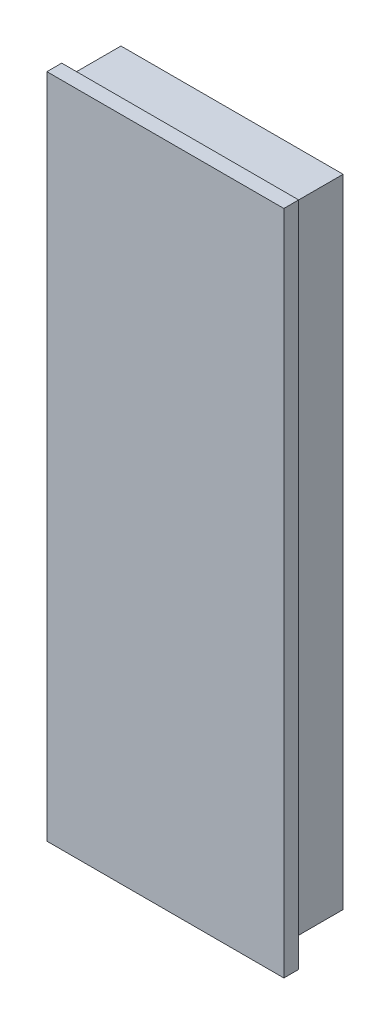
from build123d import *

# Parameters (mm, degrees)
SKETCH_1_W      = 15
SKETCH_1_H      = 43
EXTRUDE_1_DEPTH = 4
SKETCH_2_W      = 16
SKETCH_2_H      = 45
EXTRUDE_2_DEPTH = 1


with BuildPart() as part:
    # 草图1 → 凸台-拉伸1 (new body)
    with BuildSketch(Plane.XY):
        Rectangle(SKETCH_1_W, SKETCH_1_H)
    extrude(amount=EXTRUDE_1_DEPTH)

    # 草图2 → 凸台-拉伸2 (add)
    with BuildSketch(Plane.XY.offset(4)):
        with Locations((0.5, 0)):
            Rectangle(SKETCH_2_W, SKETCH_2_H)
    extrude(amount=EXTRUDE_2_DEPTH)


solid = part.part
